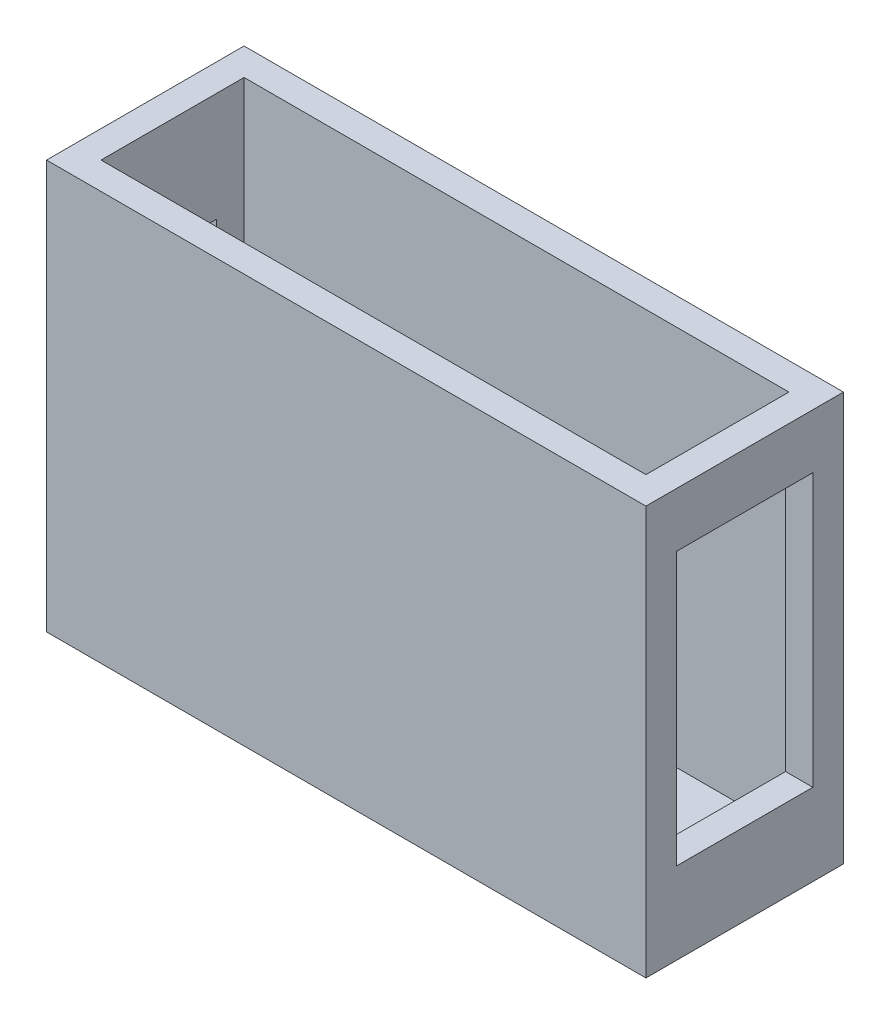
from build123d import *

# Parameters (mm, degrees)
SKETCH1_W           = 44
SKETCH1_H           = 14.5
SKETCH1_W_2         = 40
SKETCH1_H_2         = 10.5
BOSS_EXTRUDE1_DEPTH = 28
SKETCH2_W           = 44
SKETCH2_H           = 14.5
BOSS_EXTRUDE2_DEPTH = 2
CUT_EXTRUDE1_REACH  = 46
SKETCH3_W           = 6
SKETCH3_H           = 12
CUT_EXTRUDE2_REACH  = 46
SKETCH4_W           = 10
SKETCH4_H           = 20


with BuildPart() as part:
    # Sketch1 → Boss-Extrude1 (new body)
    with BuildSketch(Plane(origin=(0, 0, 0), x_dir=(1, 0, 0), z_dir=(0, 1, 0))):
        Rectangle(SKETCH1_W, SKETCH1_H)
        Rectangle(SKETCH1_W_2, SKETCH1_H_2, mode=Mode.SUBTRACT)
    extrude(amount=BOSS_EXTRUDE1_DEPTH)

    # Sketch2 → Boss-Extrude2 (add)
    with BuildSketch(Plane(origin=(0, 0, 0), x_dir=(1, 0, 0), z_dir=(0, 1, 0))):
        Rectangle(SKETCH2_W, SKETCH2_H)
    extrude(amount=-BOSS_EXTRUDE2_DEPTH)

    # Sketch3 → Cut-Extrude1 (cut, up to next)
    with BuildSketch(Plane.ZY.offset(22), mode=Mode.PRIVATE) as cut_extrude1_sk1:
        with Locations((-0.23425331, 14)):
            Rectangle(SKETCH3_W, SKETCH3_H)
    cut_extrude1_tool1 = extrude(cut_extrude1_sk1.sketch, amount=-CUT_EXTRUDE1_REACH, mode=Mode.PRIVATE) & part.part
    add(cut_extrude1_tool1.solids().sort_by_distance((-22, 14, -0.234253))[0], mode=Mode.SUBTRACT)

    # Sketch4 → Cut-Extrude2 (cut, up to next)
    with BuildSketch(Plane(origin=(22, 0, 0), x_dir=(0, 0, -1), z_dir=(1, 0, 0)), mode=Mode.PRIVATE) as cut_extrude2_sk1:
        with Locations((0, 14)):
            Rectangle(SKETCH4_W, SKETCH4_H)
    cut_extrude2_tool1 = extrude(cut_extrude2_sk1.sketch, amount=-CUT_EXTRUDE2_REACH, mode=Mode.PRIVATE) & part.part
    add(cut_extrude2_tool1.solids().sort_by_distance((22, 14, 0))[0], mode=Mode.SUBTRACT)


solid = part.part
